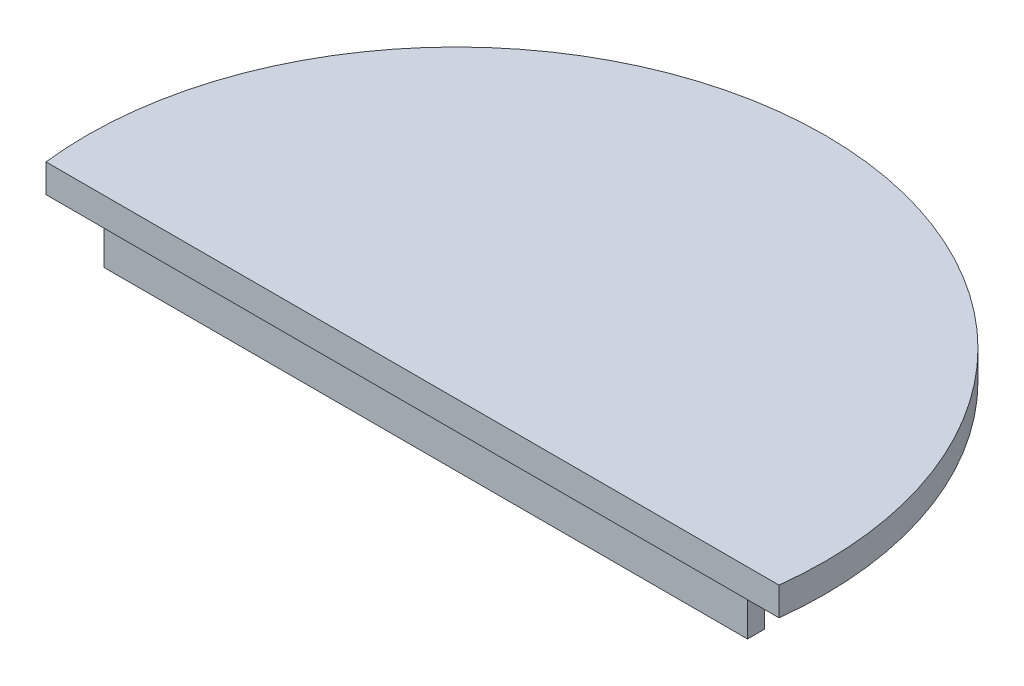
from build123d import *

# Parameters (mm, degrees)
SKETCH1_R           = 39
BOSS_EXTRUDE1_DEPTH = 3
SKETCH3_W           = 110.988465814
SKETCH3_H           = 40.72920708
CUT_EXTRUDE1_DEPTH  = 3
SKETCH4_W           = 68
SKETCH4_H           = 1.8
BOSS_EXTRUDE2_DEPTH = 5
SKETCH4_2_W         = 68
SKETCH4_2_H         = 1.8
BOSS_EXTRUDE3_DEPTH = 5


with BuildPart() as part:
    # Sketch1 → Boss-Extrude1 (new body)
    with BuildSketch(Plane(origin=(0, 0, 0), x_dir=(1, 0, 0), z_dir=(0, 1, 0))):
        Circle(SKETCH1_R)
    extrude(amount=BOSS_EXTRUDE1_DEPTH)

    # Sketch3 → Cut-Extrude1 (cut)
    with BuildSketch(Plane(origin=(0, 3, 0), x_dir=(1, 0, 0), z_dir=(0, 1, 0))):
        with Locations((0.606471885, -24.96460354)):
            Rectangle(SKETCH3_W, SKETCH3_H)
    extrude(amount=-CUT_EXTRUDE1_DEPTH, mode=Mode.SUBTRACT)

    # Sketch4 → Boss-Extrude2 (add)
    with BuildSketch(Plane.XZ):
        with Locations((0, 2.3)):
            Rectangle(SKETCH4_W, SKETCH4_H)
    extrude(amount=BOSS_EXTRUDE2_DEPTH)

    # Sketch4_2 → Boss-Extrude3 (add)
    with BuildSketch(Plane.XZ):
        with Locations((0, 2.3)):
            Rectangle(SKETCH4_2_W, SKETCH4_2_H)
    extrude(amount=BOSS_EXTRUDE3_DEPTH)


solid = part.part
